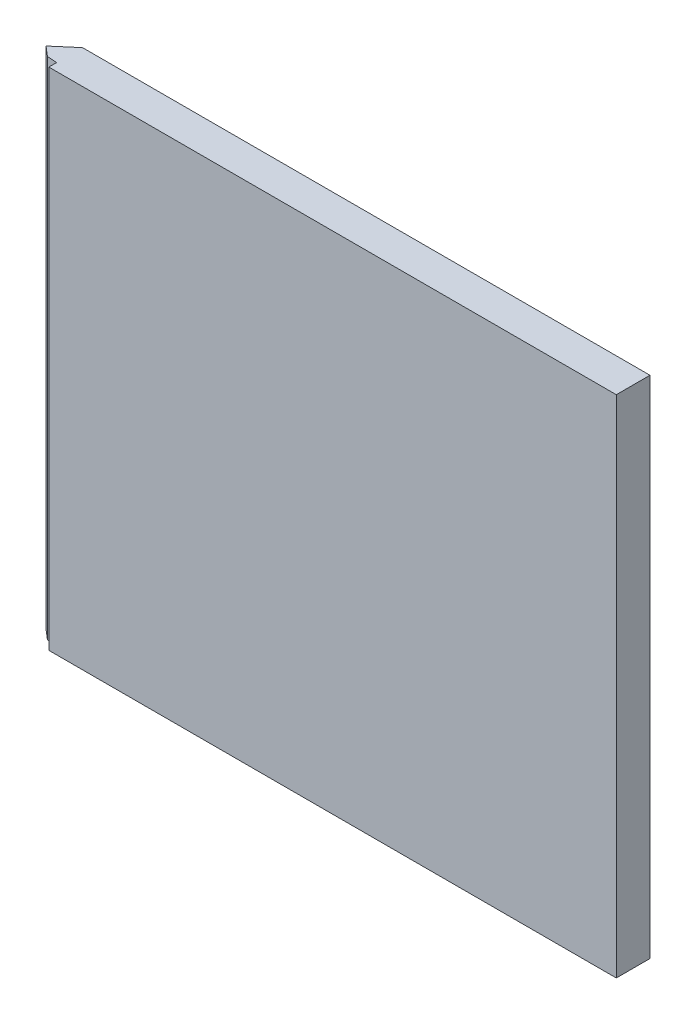
from build123d import *

# Parameters (mm, degrees)
ESQUISSE1_W             = 104.6
ESQUISSE1_H             = 90
BOSS_EXTRU_3_DEPTH      = 6
ENL_V_MAT_EXTRU_1_DEPTH = 91
ENL_V_MAT_EXTRU_2_DEPTH = 91
ENL_V_MAT_EXTRU_4_DEPTH = 90


with BuildPart() as part:
    # Esquisse1 → Boss.-Extru.3 (new body)
    with BuildSketch(Plane.XY):
        with Locations((-0.339287382, -16.126157407)):
            Rectangle(ESQUISSE1_W, ESQUISSE1_H)
    extrude(amount=BOSS_EXTRU_3_DEPTH)

    # Esquisse4 → Enlèv. mat.-Extru.1 (cut)
    with BuildSketch(Plane.XZ.offset(61.126157407)):
        Polygon((-49.138987395, 6), (-52.639287382, 6), (-52.639287382, 3), align=None)
    extrude(amount=-ENL_V_MAT_EXTRU_1_DEPTH, mode=Mode.SUBTRACT)

    # Esquisse5 → Enlèv. mat.-Extru.2 (cut)
    with BuildSketch(Plane.XZ.offset(61.126157407)):
        Polygon((-52.639287382, 3), (-49.139287382, 0), (-52.639287382, 0), align=None)
    extrude(amount=-ENL_V_MAT_EXTRU_2_DEPTH, mode=Mode.SUBTRACT)

    # Esquisse7 → Enlèv. mat.-Extru.4 (cut)
    with BuildSketch(Plane(origin=(0, -61.126157407, 0), x_dir=(-1, 0, 0), z_dir=(0, -1, 0))):
        Polygon((49.138987395, -6), (50.889137389, -4.5), (49.138987395, -4.6198399), align=None)
    extrude(amount=-ENL_V_MAT_EXTRU_4_DEPTH, mode=Mode.SUBTRACT)


solid = part.part
